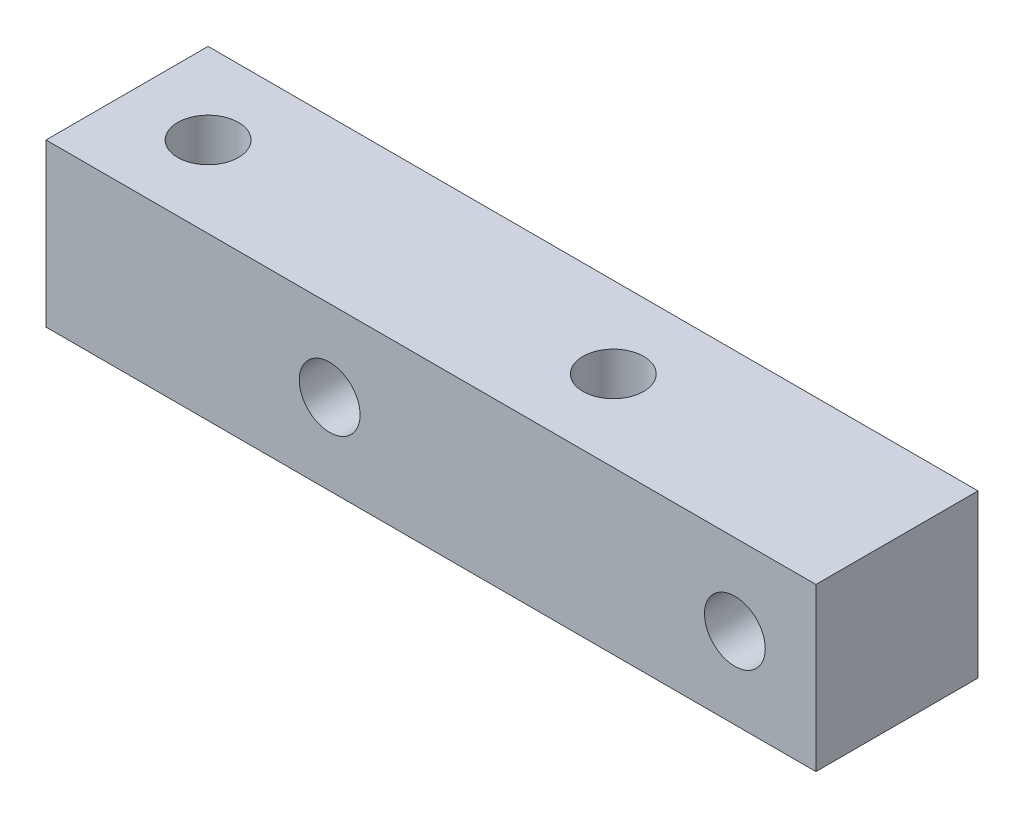
from build123d import *

# Parameters (mm, degrees)
SKETCH_1_W          = 38
SKETCH_1_H          = 8
SKETCH_1_R          = 1.5
EXTRUDE_1_DEPTH     = 8
SKETCH_2_R          = 1.5
CUT_EXTRUDE_1_DEPTH = 9


with BuildPart() as part:
    # 草图1 → 凸台-拉伸1 (new body)
    with BuildSketch(Plane(origin=(0, 0, 0), x_dir=(1, 0, 0), z_dir=(0, 1, 0))):
        Rectangle(SKETCH_1_W, SKETCH_1_H)
        with Locations((-15, 0)):
            Circle(SKETCH_1_R, mode=Mode.SUBTRACT)
        with Locations((5, 0)):
            Circle(SKETCH_1_R, mode=Mode.SUBTRACT)
    extrude(amount=EXTRUDE_1_DEPTH)

    # 草图2 → 切除-拉伸1 (cut, through all)
    with BuildSketch(Plane.XY.offset(4)):
        with Locations((-5, 4)):
            Circle(SKETCH_2_R)
        with Locations((15, 4)):
            Circle(SKETCH_2_R)
    extrude(amount=-CUT_EXTRUDE_1_DEPTH, mode=Mode.SUBTRACT)


solid = part.part
